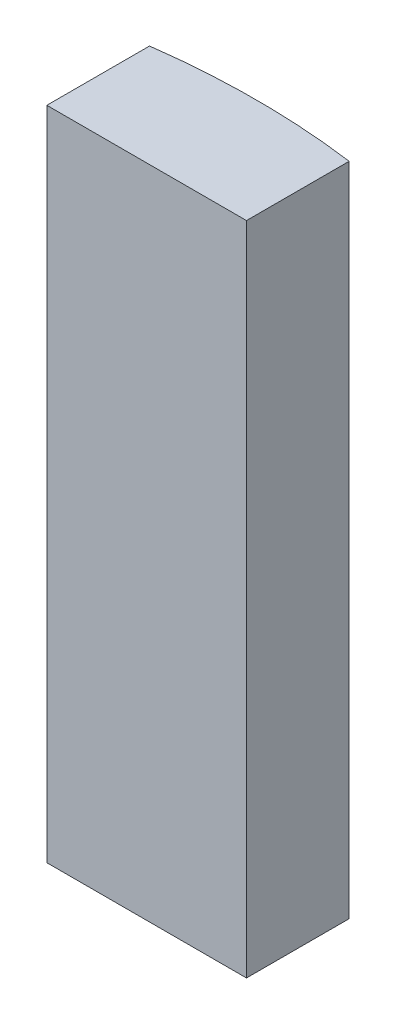
from build123d import *

# Parameters (mm, degrees)
SALIENTE_EXTRUIR1_DEPTH = 11.5


with BuildPart() as part:
    # Croquis1 → Saliente-Extruir1 (new body)
    with BuildSketch(Plane(origin=(0, 0, 0), x_dir=(1, 0, 0), z_dir=(0, 1, 0))):
        with BuildLine():
            Line((0, 2), (0, 0.2))
            Line((0, 0.2), (3.5, 0.2))
            Line((3.5, 0.2), (3.5, 2))
            ThreePointArc((3.5, 2), (1.75, 2.118326972), (0, 2))
        make_face()
    extrude(amount=SALIENTE_EXTRUIR1_DEPTH)


solid = part.part
